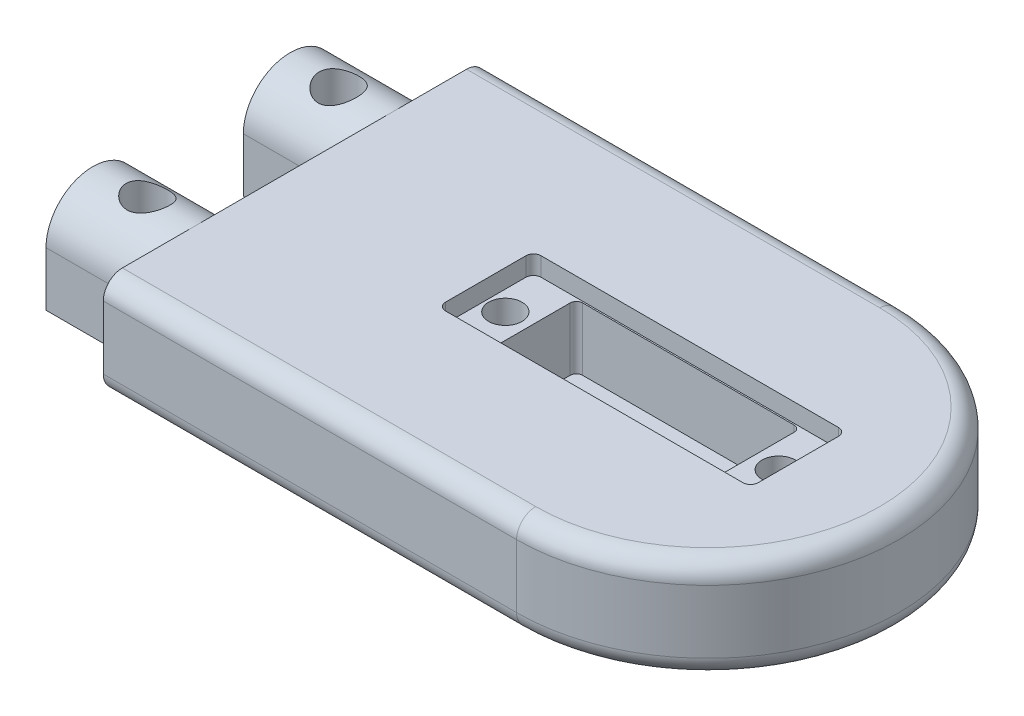
from build123d import *

# Parameters (mm, degrees)
SKETCH1_W           = 40
SKETCH1_H           = 10.610001376
BOSS_EXTRUDE1_DEPTH = 63.235
CUT_EXTRUDE1_DEPTH  = 11.610001375
CUT_EXTRUDE2_DEPTH  = 1.95
CUT_EXTRUDE3_DEPTH  = 6.56
SKETCH5_R           = 3.8
CUT_EXTRUDE4_DEPTH  = 3.100001375
SKETCH6_R           = 1.75
CUT_EXTRUDE5_DEPTH  = 4.1
SKETCH7_R           = 1.125
CUT_EXTRUDE6_DEPTH  = 2
FILLET1_R           = 2
BOSS_EXTRUDE2_DEPTH = 10.77
SKETCH9_R           = 2.125
CUT_EXTRUDE7_DEPTH  = 11.610001375


with BuildPart() as part:
    # Sketch1 → Boss-Extrude1 (new body)
    with BuildSketch(Plane(origin=(0, 0, 0), x_dir=(0, 0, -1), z_dir=(1, 0, 0))):
        Rectangle(SKETCH1_W, SKETCH1_H)
    extrude(amount=BOSS_EXTRUDE1_DEPTH)

    # Sketch2 → Cut-Extrude1 (cut, through all)
    with BuildSketch(Plane(origin=(0, 5.305000688, 0), x_dir=(1, 0, 0), z_dir=(0, 1, 0))):
        with BuildLine():
            Line((63.235, -20), (63.235, 0))
            ThreePointArc((63.235, 0), (57.377135624, -14.142135624), (43.235, -20))
            Line((43.235, -20), (63.235, -20))
        make_face()
    cut_extrude1 = extrude(amount=-CUT_EXTRUDE1_DEPTH, mode=Mode.SUBTRACT)

    # Mirror1: Cut-Extrude1 across plane
    add(cut_extrude1.mirror(Plane.XY), mode=Mode.SUBTRACT)

    # Sketch3 → Cut-Extrude2 (cut)
    with BuildSketch(Plane(origin=(0, 5.305000688, 0), x_dir=(1, 0, 0), z_dir=(0, 1, 0))):
        with BuildLine():
            Line((20, 4.2), (20, -4.2))
            ThreePointArc((20, -4.2), (20.234314575, -4.765685425), (20.8, -5))
            Line((20.8, -5), (31.17, -5))
            Line((31.17, -5), (41.54, -5))
            Line((41.54, -5), (51.91, -5))
            ThreePointArc((51.91, -5), (52.475685425, -4.765685425), (52.71, -4.2))
            Line((52.71, -4.2), (52.71, 4.2))
            ThreePointArc((52.71, 4.2), (52.475685425, 4.765685425), (51.91, 5))
            Line((51.91, 5), (41.54, 5))
            Line((41.54, 5), (31.17, 5))
            Line((31.17, 5), (20.8, 5))
            ThreePointArc((20.8, 5), (20.234314575, 4.765685425), (20, 4.2))
        make_face()
    extrude(amount=-CUT_EXTRUDE2_DEPTH, mode=Mode.SUBTRACT)

    # Sketch4 → Cut-Extrude3 (cut)
    with BuildSketch(Plane(origin=(0, 3.355000688, 0), x_dir=(1, 0, 0), z_dir=(0, 1, 0))):
        with BuildLine():
            Line((48.07, -4.2), (48.07, 4.2))
            ThreePointArc((48.07, 4.2), (47.968188406, 4.549269911), (47.694647782, 4.78912528))
            ThreePointArc((47.694647782, 4.78912528), (47.560656617, 4.834598862), (47.42, 4.85))
            Line((47.42, 4.85), (25.29, 4.85))
            ThreePointArc((25.29, 4.85), (24.830380592, 4.659619408), (24.64, 4.2))
            Line((24.64, 4.2), (24.64, -4.2))
            ThreePointArc((24.64, -4.2), (24.830380592, -4.659619408), (25.29, -4.85))
            Line((25.29, -4.85), (47.42, -4.85))
            ThreePointArc((47.42, -4.85), (47.749899473, -4.760059227), (47.988502289, -4.515127192))
            ThreePointArc((47.988502289, -4.515127192), (48.049295832, -4.362747522), (48.07, -4.2))
        make_face()
    extrude(amount=-CUT_EXTRUDE3_DEPTH, mode=Mode.SUBTRACT)

    # Sketch5 → Cut-Extrude4 (cut, through all)
    with BuildSketch(Plane(origin=(0, -3.204999312, 0), x_dir=(1, 0, 0), z_dir=(0, 1, 0))):
        with Locations((43.235, 0)):
            Circle(SKETCH5_R)
    extrude(amount=-CUT_EXTRUDE4_DEPTH, mode=Mode.SUBTRACT)

    # Sketch6 → Cut-Extrude5 (cut)
    with BuildSketch(Plane(origin=(0, 3.355000688, 0), x_dir=(1, 0, 0), z_dir=(0, 1, 0))):
        with Locations((50.655, 0)):
            Circle(SKETCH6_R)
        with Locations((22.055, 0)):
            Circle(SKETCH6_R)
    extrude(amount=-CUT_EXTRUDE5_DEPTH, mode=Mode.SUBTRACT)

    # Sketch7 → Cut-Extrude6 (cut)
    with BuildSketch(Plane(origin=(0, -0.744999312, 0), x_dir=(1, 0, 0), z_dir=(0, 1, 0))):
        with Locations((50.655, 0)):
            Circle(SKETCH7_R)
        with Locations((22.055, 0)):
            Circle(SKETCH7_R)
    extrude(amount=-CUT_EXTRUDE6_DEPTH, mode=Mode.SUBTRACT)

    # Fillet1
    fillet1_edges = [part.edges().sort_by_distance(p)[0] for p in [
        (21.6175, 5.305000688, 20),
        (21.6175, -5.305000688, 20),
        (63.235, -5.305000688, 0),
        (63.235, 5.305000688, 0),
        (21.6175, 5.305000688, -20),
        (21.6175, -5.305000688, -20),
    ]]
    fillet(fillet1_edges, radius=FILLET1_R)

    # Sketch8 → Boss-Extrude2 (add)
    with BuildSketch(Plane.ZY):
        with BuildLine():
            Line((-15.221247138, 0.365000688), (-15.221247138, -5.305000688))
            Line((-15.221247138, -5.305000688), (-5.421247138, -5.305000688))
            Line((-5.421247138, -5.305000688), (-5.421247138, 0.365000688))
            ThreePointArc((-5.421247138, 0.365000688), (-10.321247138, 5.265000688), (-15.221247138, 0.365000688))
        make_face()
        with BuildLine():
            Line((15.221247138, 0.365000688), (15.221247138, -5.305000688))
            Line((15.221247138, -5.305000688), (5.421247138, -5.305000688))
            Line((5.421247138, -5.305000688), (5.421247138, 0.365000688))
            ThreePointArc((5.421247138, 0.365000688), (10.321247138, 5.265000688), (15.221247138, 0.365000688))
        make_face()
    extrude(amount=BOSS_EXTRUDE2_DEPTH)

    # Sketch9 → Cut-Extrude7 (cut, through all)
    with BuildSketch(Plane.XZ.offset(5.305000688)):
        with Locations((-5.385, 10)):
            Circle(SKETCH9_R)
        with Locations((-5.385, -10)):
            Circle(SKETCH9_R)
    extrude(amount=-CUT_EXTRUDE7_DEPTH, mode=Mode.SUBTRACT)


solid = part.part
